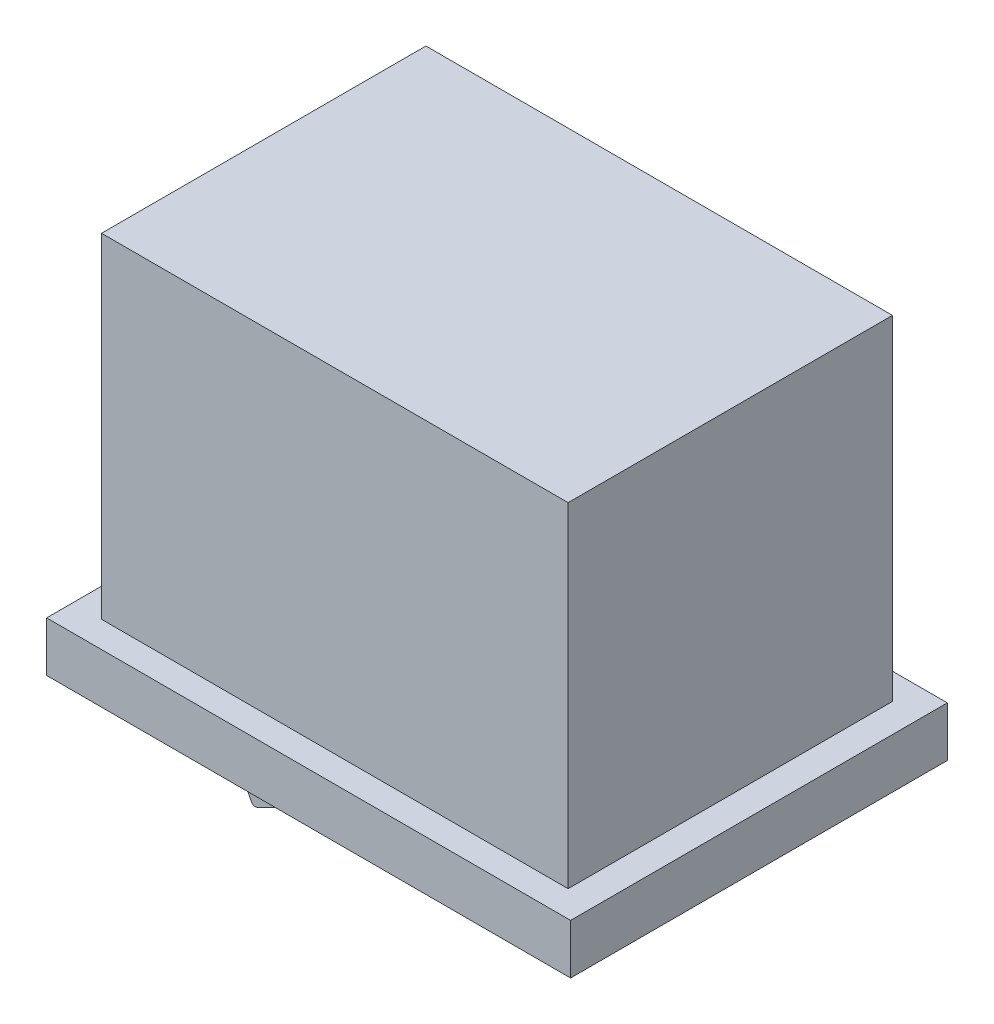
from build123d import *

# Parameters (mm, degrees)
SKETCH1_W           = 21
SKETCH1_H           = 15.4
BOSS_EXTRUDE1_DEPTH = 15.1
SKETCH3_W           = 21
SKETCH3_H           = 15.1
SKETCH3_W_2         = 18.7
SKETCH3_H_2         = 13
CUT_EXTRUDE1_DEPTH  = 13.4
SKETCH4_W           = 18
SKETCH4_H           = 10
BOSS_EXTRUDE2_DEPTH = 3
CUT_EXTRUDE2_DEPTH  = 13.55


with BuildPart() as part:
    # Sketch1 → Boss-Extrude1 (new body)
    with BuildSketch(Plane.XY):
        with Locations((10.5, -7.7)):
            Rectangle(SKETCH1_W, SKETCH1_H)
    extrude(amount=BOSS_EXTRUDE1_DEPTH)

    # Sketch3 → Cut-Extrude1 (cut)
    with BuildSketch(Plane(origin=(0, 0, 0), x_dir=(1, 0, 0), z_dir=(0, 1, 0))):
        with Locations((10.5, -7.55)):
            Rectangle(SKETCH3_W, SKETCH3_H)
        with Locations((10.5, -7.55)):
            Rectangle(SKETCH3_W_2, SKETCH3_H_2, mode=Mode.SUBTRACT)
    extrude(amount=-CUT_EXTRUDE1_DEPTH, mode=Mode.SUBTRACT)

    # Sketch4 → Boss-Extrude2 (add)
    with BuildSketch(Plane.XZ.offset(15.4)):
        with Locations((10.5, 7.55)):
            Rectangle(SKETCH4_W, SKETCH4_H)
    extrude(amount=BOSS_EXTRUDE2_DEPTH)

    # Sketch5 → Cut-Extrude2 (cut, through all)
    with BuildSketch(Plane(origin=(0, 0, 2.55), x_dir=(-1, 0, 0), z_dir=(0, 0, -1))):
        with BuildLine():
            Line((-4.318187888, -15.4), (-5.64025516, -18.208957591))
            ThreePointArc((-5.64025516, -18.208957591), (-5.758218198, -18.313607167), (-5.91534374, -18.300251418))
            add(Edge.make_bspline(
                [(-5.91534374, -18.300251418), (-9.414175538, -16.433895122), (-13.180982291, -15.465516785), (-17.200671876, -15.4)],
                knots=[0.017358171, 0.017358171, 0.017358171, 0.017358171, 1, 1, 1, 1], degree=3))
            Line((-17.200671876, -15.4), (-19.5, -15.4))
            Line((-19.5, -15.4), (-20.228637612, -15.606353341))
            Line((-20.228637612, -15.606353341), (-20.675659597, -18.662431802))
            Line((-20.675659597, -18.662431802), (-18.82613024, -20.157147076))
            Line((-18.82613024, -20.157147076), (-11.911793742, -20.360373848))
            Line((-11.911793742, -20.360373848), (-0.335637878, -21.060292332))
            Line((-0.335637878, -21.060292332), (-0.808442559, -15.4))
            Line((-0.808442559, -15.4), (-4.318187888, -15.4))
        make_face()
    extrude(amount=-CUT_EXTRUDE2_DEPTH, mode=Mode.SUBTRACT)


solid = part.part
